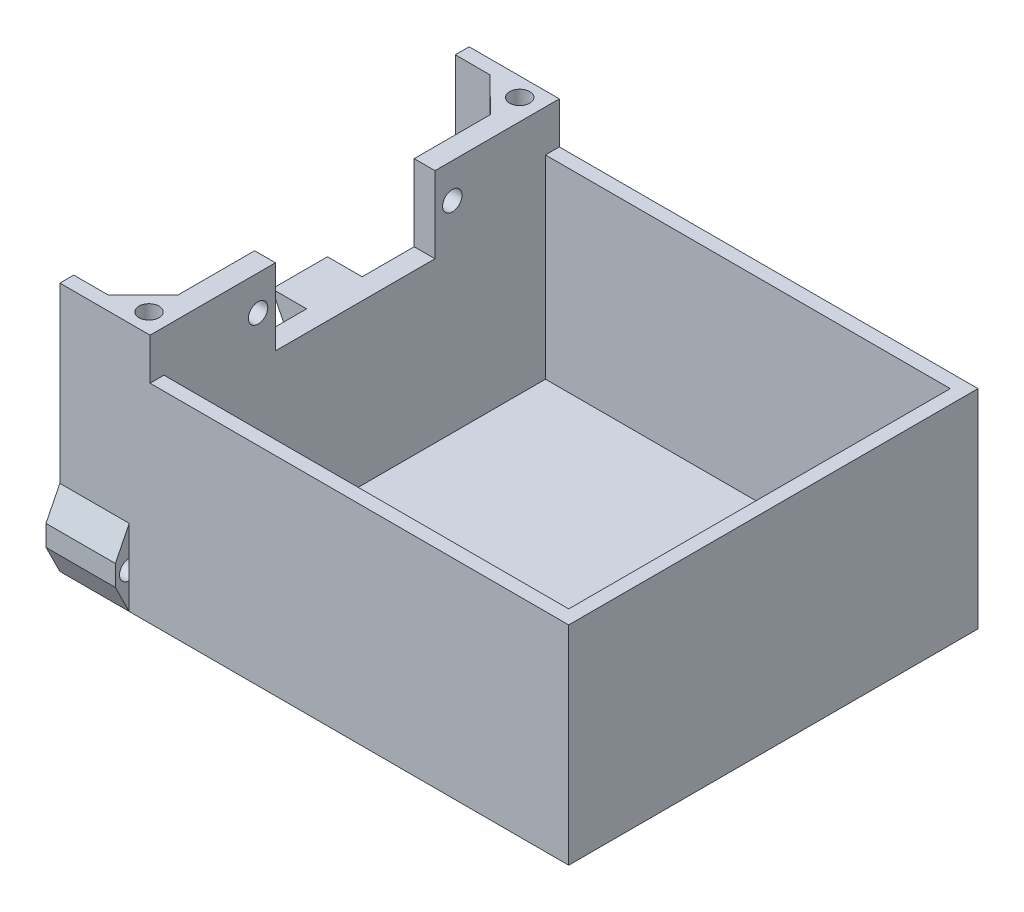
from build123d import *

# Parameters (mm, degrees)
SKETCH1_W           = 70
SKETCH1_H           = 55
BOSS_EXTRUDE1_DEPTH = 2
SKETCH2_W           = 73.35025282
SKETCH2_H           = 59
BOSS_EXTRUDE3_DEPTH = 2
BOSS_EXTRUDE4_DEPTH = 28
BOSS_EXTRUDE5_DEPTH = 34
SKETCH7_W           = 3
SKETCH7_H           = 23
CUT_EXTRUDE1_DEPTH  = 11
SKETCH9_R           = 1.4
CUT_EXTRUDE2_DEPTH  = 11
SKETCH10_W          = 8
SKETCH10_H          = 10
BOSS_EXTRUDE6_DEPTH = 5
CUT_EXTRUDE3_REACH  = 35.573
SKETCH12_W          = 13
SKETCH12_H          = 2
BOSS_EXTRUDE7_DEPTH = 6
SKETCH13_R          = 1.45
CUT_EXTRUDE4_DEPTH  = 10
BOSS_EXTRUDE8_DEPTH = 10
SKETCH15_R          = 1.4
CUT_EXTRUDE5_DEPTH  = 10


with BuildPart() as part:
    # Sketch1 → Boss-Extrude1 (new body)
    with BuildSketch(Plane(origin=(0, 0, 0), x_dir=(1, 0, 0), z_dir=(0, 1, 0))):
        with Locations((35, -27.5)):
            Rectangle(SKETCH1_W, SKETCH1_H)
    extrude(amount=BOSS_EXTRUDE1_DEPTH)

    # Sketch2 → Boss-Extrude3 (add)
    with BuildSketch(Plane(origin=(0, 0, 0), x_dir=(1, 0, 0), z_dir=(0, 1, 0))):
        with Locations((35.32487359, -27.5)):
            Rectangle(SKETCH2_W, SKETCH2_H)
    extrude(amount=BOSS_EXTRUDE3_DEPTH)

    # Sketch3 → Boss-Extrude4 (add)
    with BuildSketch(Plane(origin=(0, 2, 0), x_dir=(1, 0, 0), z_dir=(0, 1, 0))):
        Polygon((-1.35025282, 2), (72, 2), (72, -57), (-1.35025282, -57), (-1.35025282, -55), (70, -55), (70, 0), (-1.35025282, 0), align=None)
    extrude(amount=BOSS_EXTRUDE4_DEPTH)

    # Sketch5 → Boss-Extrude5 (add)
    with BuildSketch(Plane(origin=(0, 2, 0), x_dir=(1, 0, 0), z_dir=(0, 1, 0))):
        Polygon((11.64974718, 0), (8.64974718, 0), (8.64974718, -4.927247976), (8.64974718, -49.926173774), (8.64974718, -55), (11.64974718, -55), align=None)
        Polygon((8.64974718, -4.927247976), (8.64974718, 0), (3.64974718, 0), align=None)
        Polygon((8.64974718, -55), (8.64974718, -49.926173774), (3.64974718, -55), align=None)
    extrude(amount=BOSS_EXTRUDE5_DEPTH)

    # Sketch7 → Cut-Extrude1 (cut)
    with BuildSketch(Plane(origin=(0, 36, 0), x_dir=(1, 0, 0), z_dir=(0, 1, 0))):
        with Locations((10.14974718, -27.426710875)):
            Rectangle(SKETCH7_W, SKETCH7_H)
    extrude(amount=-CUT_EXTRUDE1_DEPTH, mode=Mode.SUBTRACT)

    # Sketch9 → Cut-Extrude2 (cut)
    with BuildSketch(Plane.ZY.offset(-8.64974718)):
        with Locations((13.426710875, 31)):
            Circle(SKETCH9_R)
        with Locations((41.426710875, 31)):
            Circle(SKETCH9_R)
    extrude(amount=-CUT_EXTRUDE2_DEPTH, mode=Mode.SUBTRACT)

    # Sketch10 → Boss-Extrude6 (add)
    with BuildSketch(Plane.ZY.offset(-8.64974718)):
        with Locations((27.426710875, 20)):
            Rectangle(SKETCH10_W, SKETCH10_H)
    extrude(amount=BOSS_EXTRUDE6_DEPTH)

    # Sketch11 → Cut-Extrude3 (cut, up to next)
    with BuildSketch(Plane(origin=(0, 0, 23.426710875), x_dir=(-1, 0, 0), z_dir=(0, 0, -1)), mode=Mode.PRIVATE) as cut_extrude3_sk1:
        Polygon((-8.64974718, 15), (-3.64974718, 25), (-3.64974718, 15), align=None)
    cut_extrude3_tool1 = extrude(cut_extrude3_sk1.sketch, amount=-CUT_EXTRUDE3_REACH, mode=Mode.PRIVATE) & part.part
    add(cut_extrude3_tool1.solids().sort_by_distance((5.316414, 18.333333, 23.426711))[0], mode=Mode.SUBTRACT)

    # Sketch12 → Boss-Extrude7 (add)
    with BuildSketch(Plane(origin=(0, 30, 0), x_dir=(1, 0, 0), z_dir=(0, 1, 0))):
        with Locations((5.14974718, 1)):
            Rectangle(SKETCH12_W, SKETCH12_H)
        with Locations((5.14974718, -56)):
            Rectangle(SKETCH12_W, SKETCH12_H)
    extrude(amount=BOSS_EXTRUDE7_DEPTH)

    # Sketch13 → Cut-Extrude4 (cut)
    with BuildSketch(Plane(origin=(0, 36, 0), x_dir=(1, 0, 0), z_dir=(0, 1, 0))):
        with Locations((8.61107216, -0.677247976)):
            Circle(SKETCH13_R)
        with Locations((8.673474118, -54.176173774)):
            Circle(SKETCH13_R)
    extrude(amount=-CUT_EXTRUDE4_DEPTH, mode=Mode.SUBTRACT)

    # Sketch14 → Boss-Extrude8 (add)
    with BuildSketch(Plane.ZY.offset(1.35025282)):
        Polygon((-2, 0), (-4, 4), (-4, 7), (-2, 11), align=None)
        Polygon((57, 0), (57, 11), (59, 7), (59, 4), align=None)
    extrude(amount=-BOSS_EXTRUDE8_DEPTH)

    # Sketch15 → Cut-Extrude5 (cut)
    with BuildSketch(Plane.ZY.offset(1.35025282)):
        with Locations((-2, 5.25)):
            Circle(SKETCH15_R)
        with Locations((57, 5.25)):
            Circle(SKETCH15_R)
    extrude(amount=-CUT_EXTRUDE5_DEPTH, mode=Mode.SUBTRACT)


solid = part.part
